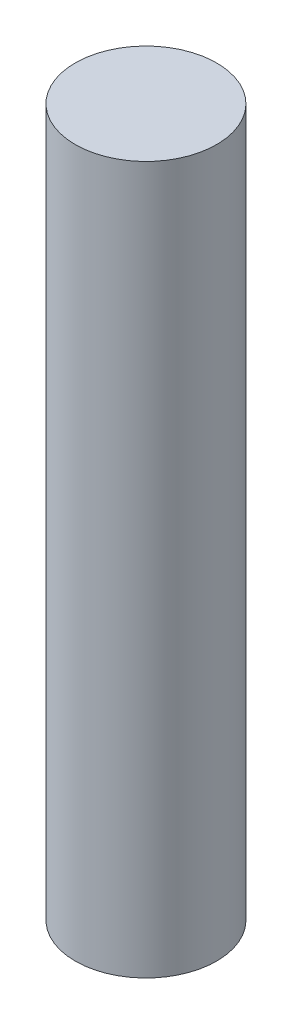
from build123d import *

# Parameters (mm, degrees)
SKETCH1_R           = 17.78
BOSS_EXTRUDE1_DEPTH = 177.8
SKETCH4_R           = 3.175
CUT_EXTRUDE1_DEPTH  = 152.4


with BuildPart() as part:
    # Sketch1 → Boss-Extrude1 (new body)
    with BuildSketch(Plane(origin=(0, 0, 0), x_dir=(1, 0, 0), z_dir=(0, 1, 0))):
        Circle(SKETCH1_R)
    extrude(amount=BOSS_EXTRUDE1_DEPTH)

    # Sketch4 → Cut-Extrude1 (cut)
    with BuildSketch(Plane.XZ):
        Circle(SKETCH4_R)
    extrude(amount=-CUT_EXTRUDE1_DEPTH, mode=Mode.SUBTRACT)


solid = part.part
